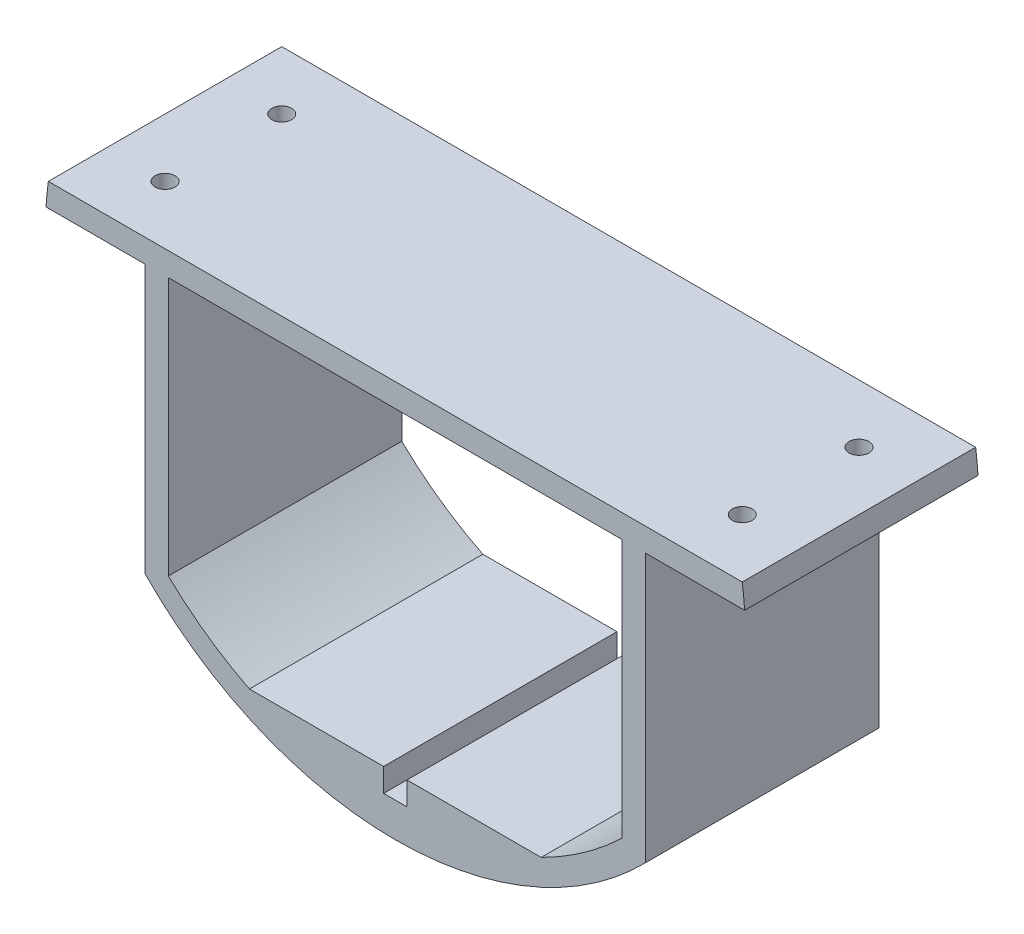
from build123d import *

# Parameters (mm, degrees)
SKETCH2_R           = 76.2
BOSS_EXTRUDE1_DEPTH = 50.8
CUT_EXTRUDE1_DEPTH  = 76.2
CUT_EXTRUDE2_DEPTH  = 76.2
SKETCH8_W           = 5.08
SKETCH8_H           = 5.08
CUT_EXTRUDE4_DEPTH  = 50.8
CUT_EXTRUDE5_DEPTH  = 51.8
SKETCH10_R          = 2.159
CUT_EXTRUDE6_DEPTH  = 25.4


with BuildPart() as part:
    # Sketch2 → Boss-Extrude1 (new body)
    with BuildSketch(Plane.XY):
        Circle(SKETCH2_R)
    extrude(amount=BOSS_EXTRUDE1_DEPTH)

    # Sketch4 → Cut-Extrude1 (cut)
    with BuildSketch(Plane.XY.offset(50.8)):
        with BuildLine():
            Line((-75.519629236, 10.16), (75.519629236, 10.16))
            ThreePointArc((75.519629236, 10.16), (0, 76.2), (-75.519629236, 10.16))
        make_face()
    extrude(amount=-CUT_EXTRUDE1_DEPTH, mode=Mode.SUBTRACT)

    # Sketch5 → Cut-Extrude2 (cut)
    with BuildSketch(Plane.XY.offset(50.8)):
        with BuildLine():
            Line((49.396930897, 5.08), (-49.396930897, 5.08))
            Line((-49.396930897, 5.08), (-49.396930897, -51.166371944))
            ThreePointArc((-49.396930897, -51.166371944), (-41.049983197, -58.077132157), (-31.75, -63.639546667))
            Line((-31.75, -63.639546667), (31.75, -63.639546667))
            ThreePointArc((31.75, -63.639546667), (41.049983197, -58.077132157), (49.396930897, -51.166371944))
            Line((49.396930897, -51.166371944), (49.396930897, 5.08))
        make_face()
    extrude(amount=-CUT_EXTRUDE2_DEPTH, mode=Mode.SUBTRACT)

    # Sketch8 → Cut-Extrude4 (cut)
    with BuildSketch(Plane.XY.offset(50.8)):
        with Locations((0, -66.179546667)):
            Rectangle(SKETCH8_W, SKETCH8_H)
    extrude(amount=-CUT_EXTRUDE4_DEPTH, mode=Mode.SUBTRACT)

    # Sketch9 → Cut-Extrude5 (cut, through all)
    with BuildSketch(Plane.XY.offset(50.8)):
        with BuildLine():
            Line((54.476930897, 5.08), (76.030478099, 5.08))
            ThreePointArc((76.030478099, 5.08), (71.480790805, -26.399555791), (54.476930897, -53.279489487))
            Line((54.476930897, -53.279489487), (54.476930897, 5.08))
        make_face()
        with BuildLine():
            Line((-54.476930897, 5.08), (-54.476930897, -53.279489487))
            ThreePointArc((-54.476930897, -53.279489487), (-71.480790805, -26.399555791), (-76.030478099, 5.08))
            Line((-76.030478099, 5.08), (-54.476930897, 5.08))
        make_face()
    extrude(amount=-CUT_EXTRUDE5_DEPTH, mode=Mode.SUBTRACT)

    # Sketch10 → Cut-Extrude6 (cut)
    with BuildSketch(Plane(origin=(0, 10.16, 0), x_dir=(1, 0, 0), z_dir=(0, 1, 0))):
        with Locations((-62.819629236, -12.7)):
            Circle(SKETCH10_R)
        with Locations((-62.819629236, -38.1)):
            Circle(SKETCH10_R)
        with Locations((62.819629236, -12.7)):
            Circle(SKETCH10_R)
        with Locations((62.819629236, -38.1)):
            Circle(SKETCH10_R)
    extrude(amount=-CUT_EXTRUDE6_DEPTH, mode=Mode.SUBTRACT)


solid = part.part
